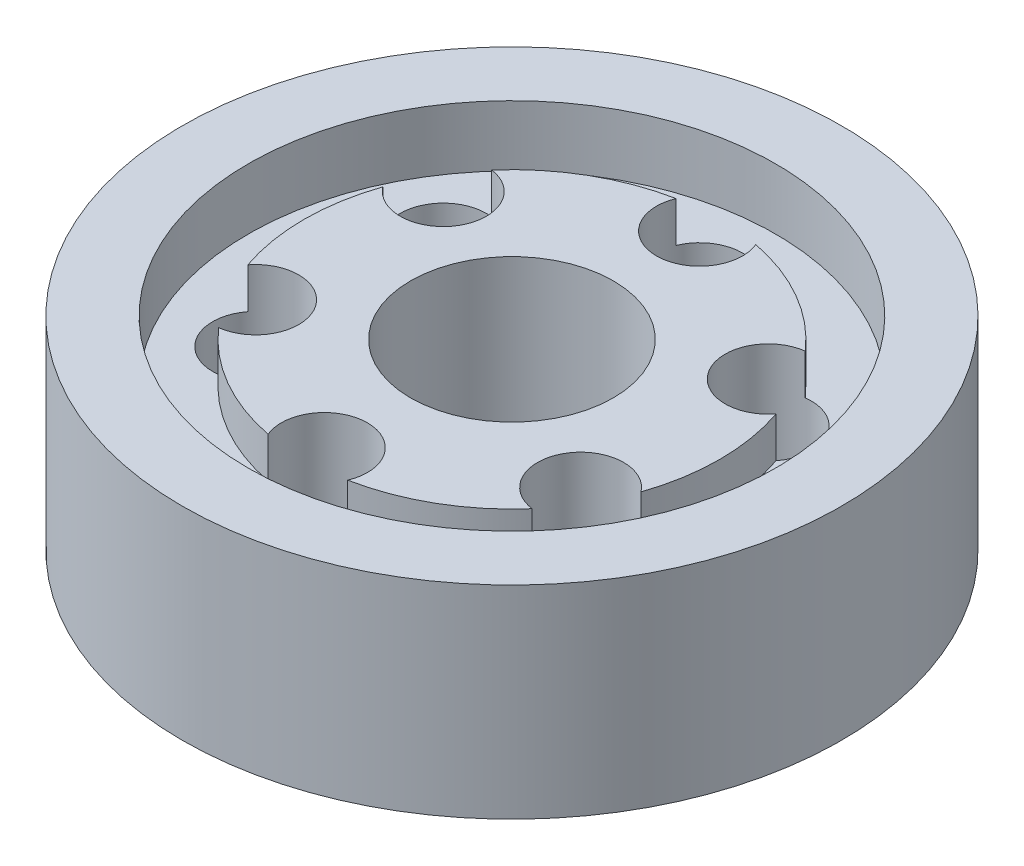
from build123d import *

# Parameters (mm, degrees)
SKETCH1_R           = 32.5
BOSS_EXTRUDE1_DEPTH = 20
SKETCH2_R           = 26
CUT_EXTRUDE1_DEPTH  = 6
SKETCH3_R           = 20.5
BOSS_EXTRUDE2_DEPTH = 4
SKETCH8_R           = 10
CUT_EXTRUDE2_DEPTH  = 21
CIRPATTERN1_COUNT   = 6


with BuildPart() as part:
    # Sketch1 → Boss-Extrude1 (new body)
    with BuildSketch(Plane(origin=(0, 0, 0), x_dir=(1, 0, 0), z_dir=(0, 1, 0))):
        Circle(SKETCH1_R)
    extrude(amount=BOSS_EXTRUDE1_DEPTH)

    # Sketch2 → Cut-Extrude1 (cut)
    with BuildSketch(Plane(origin=(0, 20, 0), x_dir=(1, 0, 0), z_dir=(0, 1, 0))):
        Circle(SKETCH2_R)
    extrude(amount=-CUT_EXTRUDE1_DEPTH, mode=Mode.SUBTRACT)

    # Sketch3 → Boss-Extrude2 (add)
    with BuildSketch(Plane(origin=(0, 14, 0), x_dir=(1, 0, 0), z_dir=(0, 1, 0))):
        Circle(SKETCH3_R)
    extrude(amount=BOSS_EXTRUDE2_DEPTH)

    # Sketch6 → M10 Tapped Hole1 (revolve, cut)
    with BuildSketch(Plane(origin=(0, 0, 18.5), x_dir=(0, 0, -1), z_dir=(1, 0, 0))):
        Polygon((0, 0), (0, 37.053657631), (4.25, 34.5), (4.25, 0), align=None)
    m10_tapped_hole1 = revolve(axis=Axis((0, -6.35, 18.5), (0, 1, 0)), mode=Mode.SUBTRACT)

    # Sketch8 → Cut-Extrude2 (cut, through all)
    with BuildSketch(Plane.XZ):
        Circle(SKETCH8_R)
    extrude(amount=-CUT_EXTRUDE2_DEPTH, mode=Mode.SUBTRACT)

    # CirPattern1: M10 Tapped Hole1 ×6 about axis
    cirpattern1_axis = Axis((0, 0, 0), (0, 1, 0))
    for i in range(1, CIRPATTERN1_COUNT):
        add(m10_tapped_hole1.rotate(cirpattern1_axis, i * 360 / CIRPATTERN1_COUNT), mode=Mode.SUBTRACT)


solid = part.part
